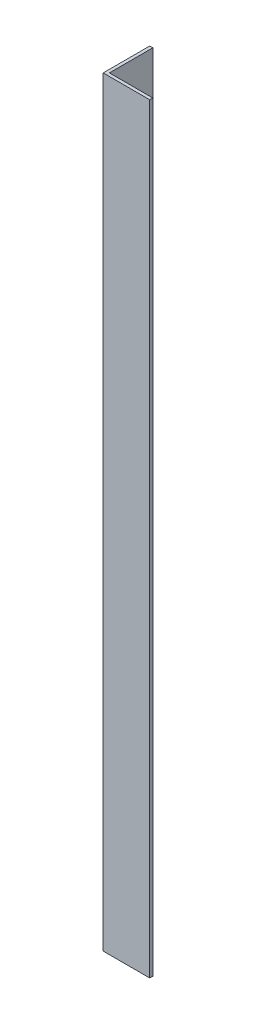
from build123d import *

# Parameters (mm, degrees)
EXTRUDE_1_DEPTH = 245


with BuildPart() as part:
    # Эскиз1 → Бобышка-Вытянуть1 (new body)
    with BuildSketch(Plane(origin=(0, 0, 0), x_dir=(1, 0, 0), z_dir=(0, 1, 0))):
        Polygon((0, 0), (0, 15), (1, 15), (1, 1), (15, 1), (15, 0), align=None)
    extrude(amount=EXTRUDE_1_DEPTH)


solid = part.part
